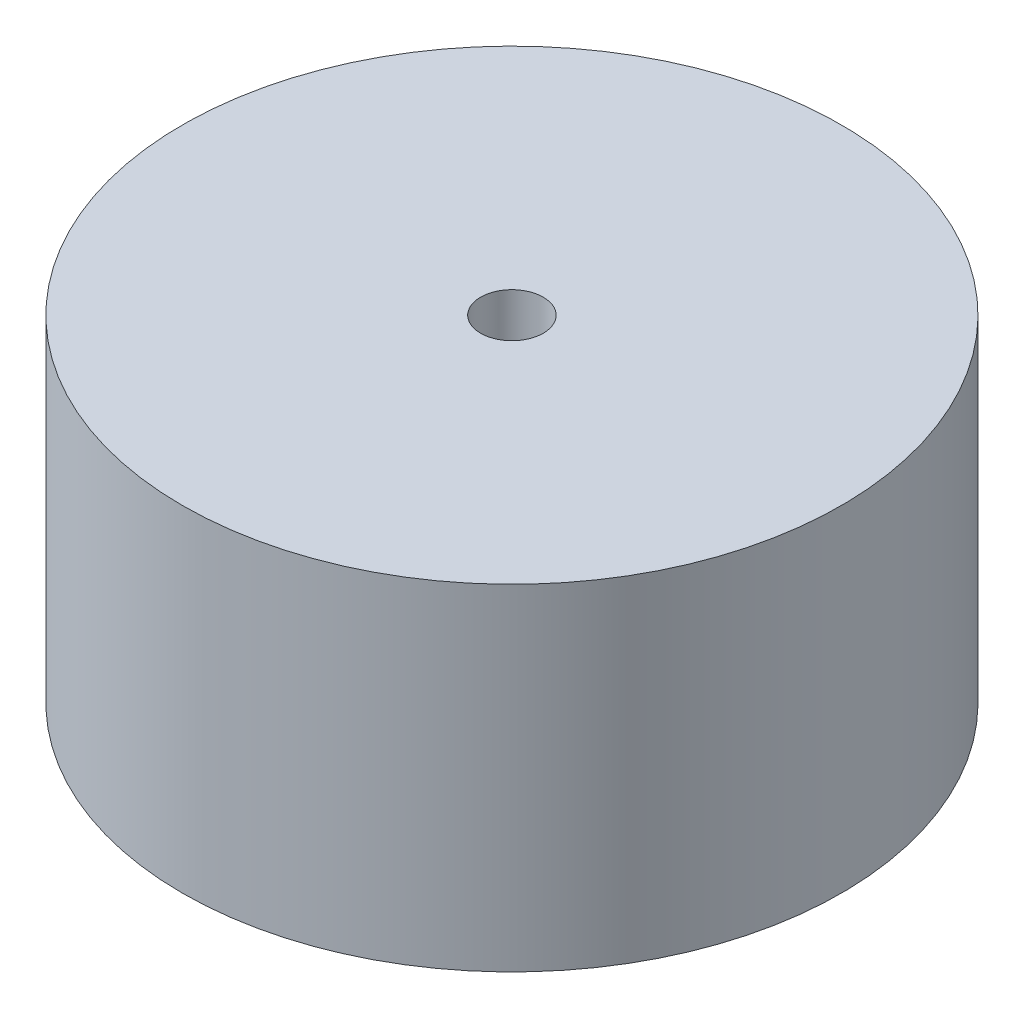
from build123d import *

# Parameters (mm, degrees)
SKETCH1_R           = 17.375
BOSS_EXTRUDE1_DEPTH = 17.7
SKETCH7_R           = 13.545
CUT_EXTRUDE4_DEPTH  = 5
SKETCH10_R          = 3.485
BOSS_EXTRUDE3_DEPTH = 1
SKETCH11_R          = 1.65
CUT_EXTRUDE5_DEPTH  = 13.7


with BuildPart() as part:
    # Sketch1 → Boss-Extrude1 (new body)
    with BuildSketch(Plane(origin=(0, 0, 0), x_dir=(1, 0, 0), z_dir=(0, 1, 0))):
        Circle(SKETCH1_R)
    extrude(amount=BOSS_EXTRUDE1_DEPTH)

    # Sketch7 → Cut-Extrude4 (cut)
    with BuildSketch(Plane.XZ):
        Circle(SKETCH7_R)
    extrude(amount=-CUT_EXTRUDE4_DEPTH, mode=Mode.SUBTRACT)

    # Sketch10 → Boss-Extrude3 (add)
    with BuildSketch(Plane.XZ.offset(-5)):
        Circle(SKETCH10_R)
    extrude(amount=BOSS_EXTRUDE3_DEPTH)

    # Sketch11 → Cut-Extrude5 (cut)
    with BuildSketch(Plane.XZ.offset(-4)):
        Circle(SKETCH11_R)
    extrude(amount=-CUT_EXTRUDE5_DEPTH, mode=Mode.SUBTRACT)


solid = part.part
